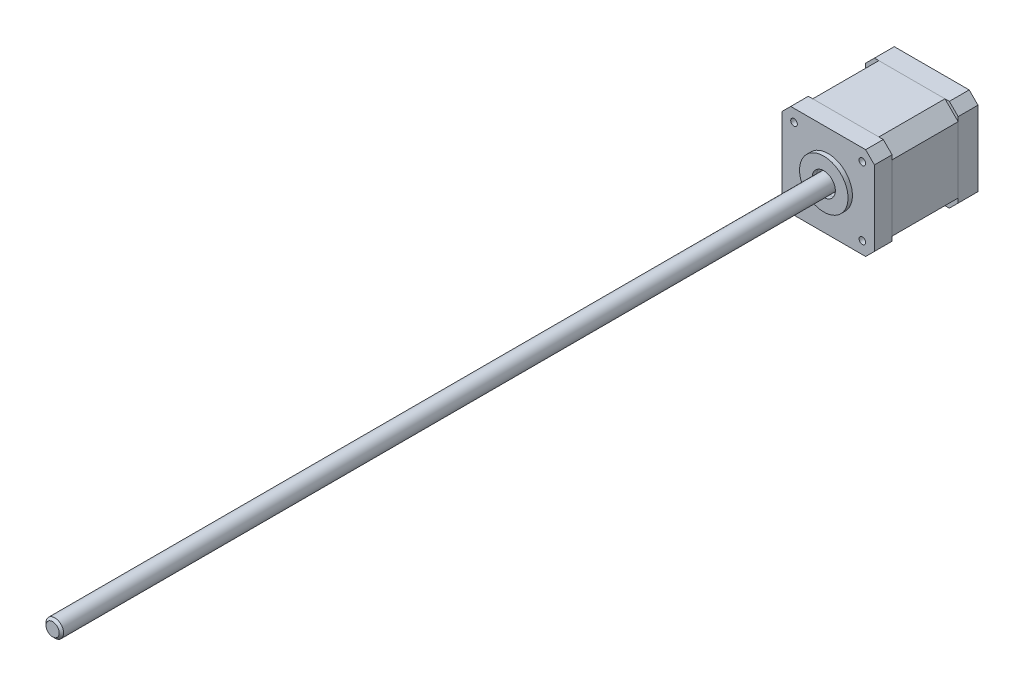
from build123d import *

# Parameters (mm, degrees)
SKETCH_1_W               = 42
SKETCH_1_H               = 42
EXTRUDE_1_DEPTH          = 15
CHAMFER_1_SIZE           = 6
SKETCH_15_W              = 42
SKETCH_15_H              = 42
EXTRUDE_11_DEPTH         = 8
SKETCH_16_W              = 42
SKETCH_16_H              = 42
EXTRUDE_12_DEPTH         = 9
CHAMFER_2_SIZE           = 4
CHAMFER_3_SIZE           = 4
SKETCH_2_R               = 11
EXTRUDE_2_DEPTH          = 2
SKETCH_3_R               = 5.25
CUT_EXTRUDE_1_DEPTH      = 5
SKETCH_6_R               = 4
EXTRUDE_9_DEPTH          = 352
SKETCH_8_R               = 1.5
CUT_EXTRUDE_3_DEPTH      = 4.5
PATTERN_CIRCULAR_1_COUNT = 4
CHAMFER_4_SIZE           = 1


with BuildPart() as part:
    # Sketch 1 → Extrude 1 (new body, symmetric)
    with BuildSketch(Plane.XY):
        Rectangle(SKETCH_1_W, SKETCH_1_H)
    extrude(amount=EXTRUDE_1_DEPTH, both=True)

    # Chamfer 1
    chamfer_1_edges = [part.edges().sort_by_distance(p)[0] for p in [
        (21, -21, 0),
        (-21, -21, 0),
        (-21, 21, 0),
        (21, 21, 0),
    ]]
    chamfer(chamfer_1_edges, length=CHAMFER_1_SIZE)


with BuildPart() as body_2:
    # Sketch 15 → Extrude 11 (new body)
    with BuildSketch(Plane.XY.offset(15)):
        Rectangle(SKETCH_15_W, SKETCH_15_H)
    extrude(amount=EXTRUDE_11_DEPTH)

    # Chamfer 2
    chamfer_2_edges = [body_2.edges().sort_by_distance(p)[0] for p in [
        (21, -21, 19),
        (-21, -21, 19),
        (-21, 21, 19),
        (21, 21, 19),
    ]]
    chamfer(chamfer_2_edges, length=CHAMFER_2_SIZE)


with BuildPart() as body_3:
    # Sketch 16 → Extrude 12 (new body)
    with BuildSketch(Plane(origin=(0, 0, -15), x_dir=(-1, 0, 0), z_dir=(0, 0, -1))):
        Rectangle(SKETCH_16_W, SKETCH_16_H)
    extrude(amount=EXTRUDE_12_DEPTH)

    # Chamfer 3
    chamfer_3_edges = [body_3.edges().sort_by_distance(p)[0] for p in [
        (-21, -21, -19.5),
        (21, -21, -19.5),
        (21, 21, -19.5),
        (-21, 21, -19.5),
    ]]
    chamfer(chamfer_3_edges, length=CHAMFER_3_SIZE)


with BuildPart() as body_4:
    # Sketch 2 → Extrude 2 (new body)
    with BuildSketch(Plane.XY.offset(23)):
        Circle(SKETCH_2_R)
    extrude(amount=EXTRUDE_2_DEPTH)


with BuildPart() as cut_extrude_1_tool:
    # Sketch 3 → Cut-Extrude 1 (new body)
    with BuildSketch(Plane.XY.offset(25)):
        Circle(SKETCH_3_R)
    extrude(amount=-CUT_EXTRUDE_1_DEPTH)


with BuildPart() as body_2_1:
    add(body_2.part)

    # Cut-Extrude 1: cut by cut_extrude_1_tool
    add(cut_extrude_1_tool.part, mode=Mode.SUBTRACT)

    # Sketch 8 → Cut-Extrude 3 (cut)
    with BuildSketch(Plane.XY.offset(23)):
        with Locations((-15.5, 15.5)):
            Circle(SKETCH_8_R)
    cut_extrude_3 = extrude(amount=-CUT_EXTRUDE_3_DEPTH, mode=Mode.SUBTRACT)

    # Pattern Circular 1: Cut-Extrude 3 ×4 about axis
    pattern_circular_1_axis = Axis((0, 0, 0), (0, 0, 1))
    for i in range(1, PATTERN_CIRCULAR_1_COUNT):
        add(cut_extrude_3.rotate(pattern_circular_1_axis, i * 360 / PATTERN_CIRCULAR_1_COUNT), mode=Mode.SUBTRACT)


with BuildPart() as body_4_1:
    add(body_4.part)

    # Cut-Extrude 1: cut by cut_extrude_1_tool
    add(cut_extrude_1_tool.part, mode=Mode.SUBTRACT)


with BuildPart() as body_5:
    # Sketch 6 → Extrude 9 (new body)
    with BuildSketch(Plane.XY.offset(23)):
        Circle(SKETCH_6_R)
    extrude(amount=EXTRUDE_9_DEPTH)

    # Chamfer 4
    chamfer_4_edges = [body_5.edges().sort_by_distance(p)[0] for p in [
        (-4, 0, 375),
    ]]
    chamfer(chamfer_4_edges, length=CHAMFER_4_SIZE)


solid = Compound([part.part, body_3.part, body_2_1.part, body_4_1.part, body_5.part])
